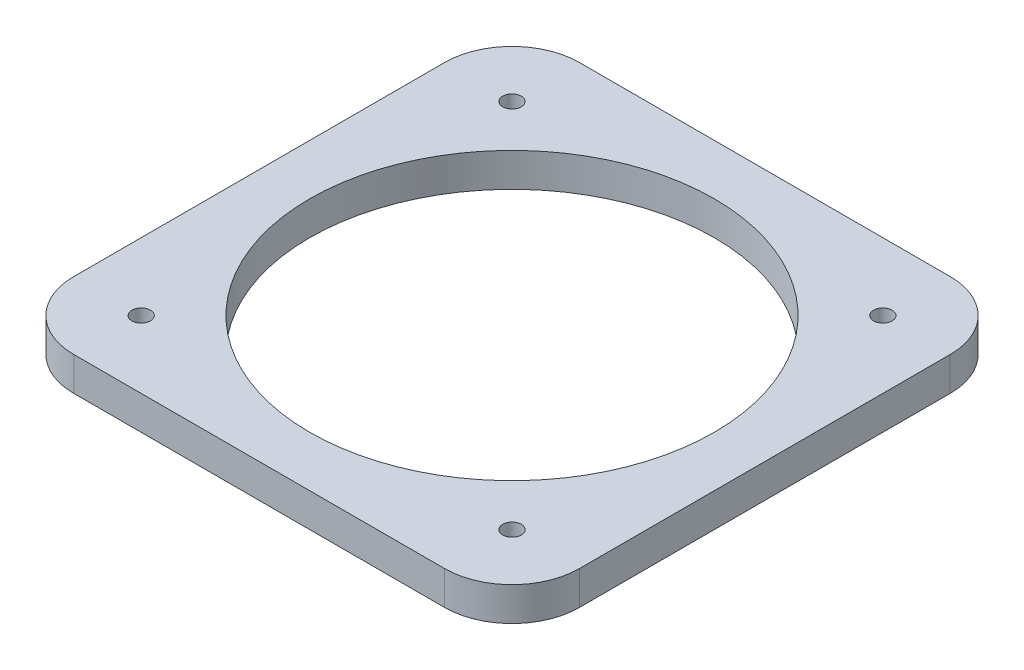
from build123d import *

# Parameters (mm, degrees)
SKETCH1_W           = 95.25
SKETCH1_H           = 95.25
SKETCH1_R           = 38.1
BOSS_EXTRUDE1_DEPTH = 6.35
SKETCH2_R           = 1.75
CUT_EXTRUDE1_DEPTH  = 7.35
CIRPATTERN1_COUNT   = 4
FILLET1_R           = 12.7


with BuildPart() as part:
    # Sketch1 → Boss-Extrude1 (new body)
    with BuildSketch(Plane(origin=(0, 0, 0), x_dir=(1, 0, 0), z_dir=(0, 1, 0))):
        Rectangle(SKETCH1_W, SKETCH1_H)
        Circle(SKETCH1_R, mode=Mode.SUBTRACT)
    extrude(amount=BOSS_EXTRUDE1_DEPTH)

    # Sketch2 → Cut-Extrude1 (cut, through all)
    with BuildSketch(Plane(origin=(0, 6.35, 0), x_dir=(1, 0, 0), z_dir=(0, 1, 0))):
        with Locations((-34.925, 34.925)):
            Circle(SKETCH2_R)
    cut_extrude1 = extrude(amount=-CUT_EXTRUDE1_DEPTH, mode=Mode.SUBTRACT)

    # CirPattern1: Cut-Extrude1 ×4 about axis
    cirpattern1_axis = Axis((0, 0, 0), (0, 1, 0))
    for i in range(1, CIRPATTERN1_COUNT):
        add(cut_extrude1.rotate(cirpattern1_axis, i * 360 / CIRPATTERN1_COUNT), mode=Mode.SUBTRACT)

    # Fillet1
    fillet1_edges = [part.edges().sort_by_distance(p)[0] for p in [
        (-47.625, 3.175, -47.625),
        (47.625, 3.175, -47.625),
        (47.625, 3.175, 47.625),
        (-47.625, 3.175, 47.625),
    ]]
    fillet(fillet1_edges, radius=FILLET1_R)


solid = part.part
